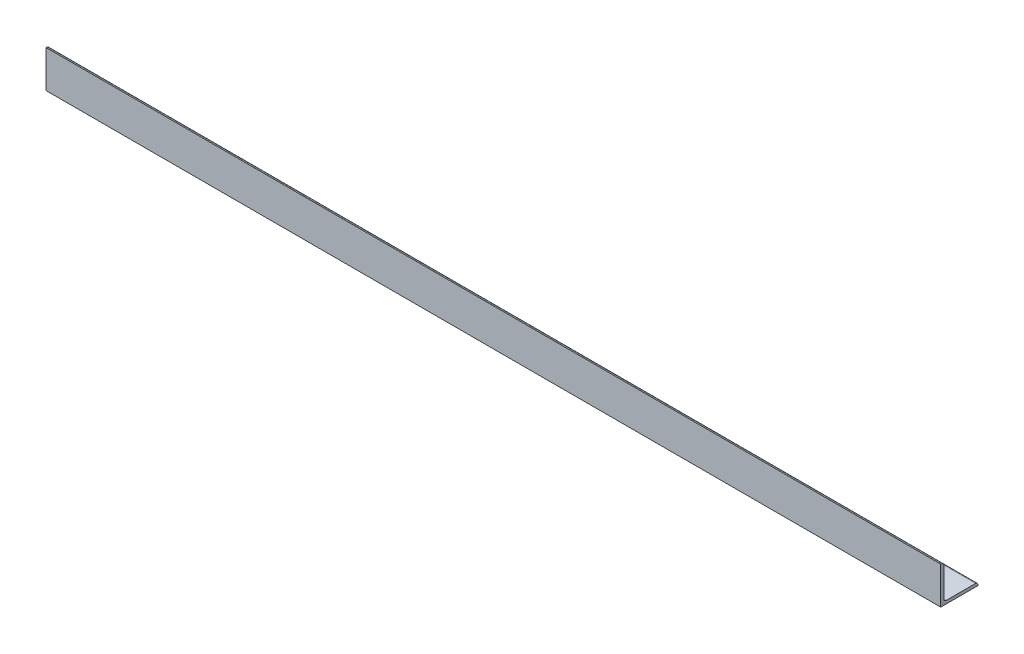
from build123d import *

# Parameters (mm, degrees)
BOSS_EXTRUDE1_DEPTH      = 914.4
BOSS_EXTRUDE1_DEPTH_BACK = 914.4


with BuildPart() as part:
    # Sketch1 → Boss-Extrude1 (new body, two sides)
    with BuildSketch(Plane(origin=(0, 0, 0), x_dir=(0, 0, -1), z_dir=(1, 0, 0))) as boss_extrude1_sk:
        with BuildLine():
            Line((0, 76.2), (0, 0))
            Line((0, 0), (76.2, 0))
            Line((76.2, 0), (76.2, 1.27))
            ThreePointArc((76.2, 1.27), (74.712102448, 4.862102448), (71.12, 6.35))
            Line((71.12, 6.35), (11.43, 6.35))
            ThreePointArc((11.43, 6.35), (7.837897552, 7.837897552), (6.35, 11.43))
            Line((6.35, 11.43), (6.35, 71.12))
            ThreePointArc((6.35, 71.12), (4.862102448, 74.712102448), (1.27, 76.2))
            Line((1.27, 76.2), (0, 76.2))
        make_face()
    extrude(amount=BOSS_EXTRUDE1_DEPTH)
    extrude(boss_extrude1_sk.sketch, amount=-BOSS_EXTRUDE1_DEPTH_BACK)


solid = part.part
